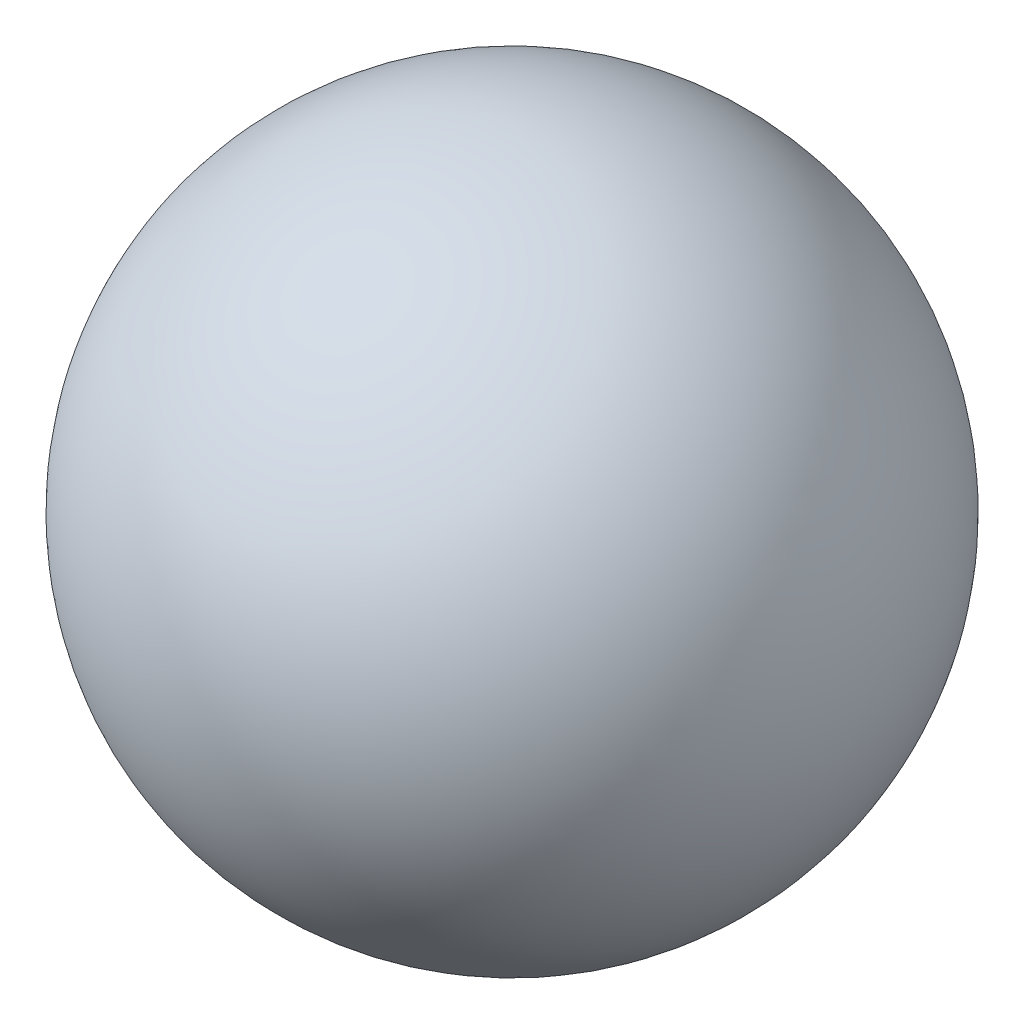
from build123d import *


with BuildPart() as part:
    # Esquisse1 → Base-Révolution (revolve)
    with BuildSketch(Plane(origin=(0, 0, 0), x_dir=(1, 0, 0), z_dir=(0, 1, 0))):
        with BuildLine():
            Line((1.65, 3.95), (6.75, 3.95))
            ThreePointArc((6.75, 3.95), (4.2, 6.5), (1.65, 3.95))
        make_face()
    revolve(axis=Axis((-0.3, 0, -3.95), (1, 0, 0)))


solid = part.part
